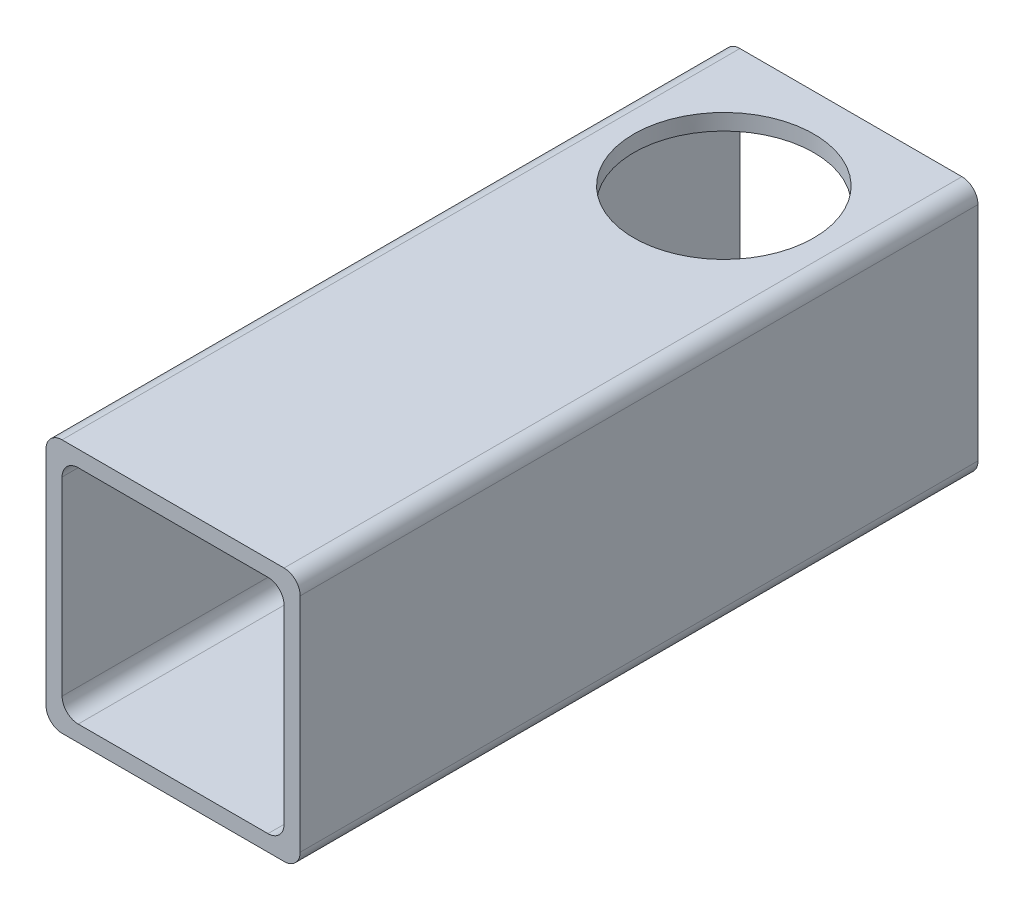
from build123d import *

# Parameters (mm, degrees)
BOSS_EXTRUDE1_DEPTH = 101.6
SKETCH2_R           = 13.49375
CUT_EXTRUDE1_DEPTH  = 228.6


with BuildPart() as part:
    # Sketch1 → Boss-Extrude1 (new body)
    with BuildSketch(Plane.XY):
        with BuildLine():
            Line((-16.637, -19.05), (16.637, -19.05))
            ThreePointArc((16.637, -19.05), (18.343248663, -18.343248663), (19.05, -16.637))
            Line((19.05, -16.637), (19.05, 16.637))
            ThreePointArc((19.05, 16.637), (18.343248663, 18.343248663), (16.637, 19.05))
            Line((16.637, 19.05), (-16.637, 19.05))
            ThreePointArc((-16.637, 19.05), (-18.343248663, 18.343248663), (-19.05, 16.637))
            Line((-19.05, 16.637), (-19.05, -16.637))
            ThreePointArc((-19.05, -16.637), (-18.343248663, -18.343248663), (-16.637, -19.05))
        make_face()
        with BuildLine():
            Line((-14.224, -16.637), (14.224, -16.637))
            ThreePointArc((14.224, -16.637), (15.930248663, -15.930248663), (16.637, -14.224))
            Line((16.637, -14.224), (16.637, 14.224))
            ThreePointArc((16.637, 14.224), (15.930248663, 15.930248663), (14.224, 16.637))
            Line((14.224, 16.637), (-14.224, 16.637))
            ThreePointArc((-14.224, 16.637), (-15.930248663, 15.930248663), (-16.637, 14.224))
            Line((-16.637, 14.224), (-16.637, -14.224))
            ThreePointArc((-16.637, -14.224), (-15.930248663, -15.930248663), (-14.224, -16.637))
        make_face(mode=Mode.SUBTRACT)
    extrude(amount=BOSS_EXTRUDE1_DEPTH)

    # Sketch2 → Cut-Extrude1 (cut, symmetric)
    with BuildSketch(Plane(origin=(0, 0, 0), x_dir=(1, 0, 0), z_dir=(0, 1, 0))):
        with Locations((0, -19.05)):
            Circle(SKETCH2_R)
    extrude(amount=CUT_EXTRUDE1_DEPTH, both=True, mode=Mode.SUBTRACT)


solid = part.part
